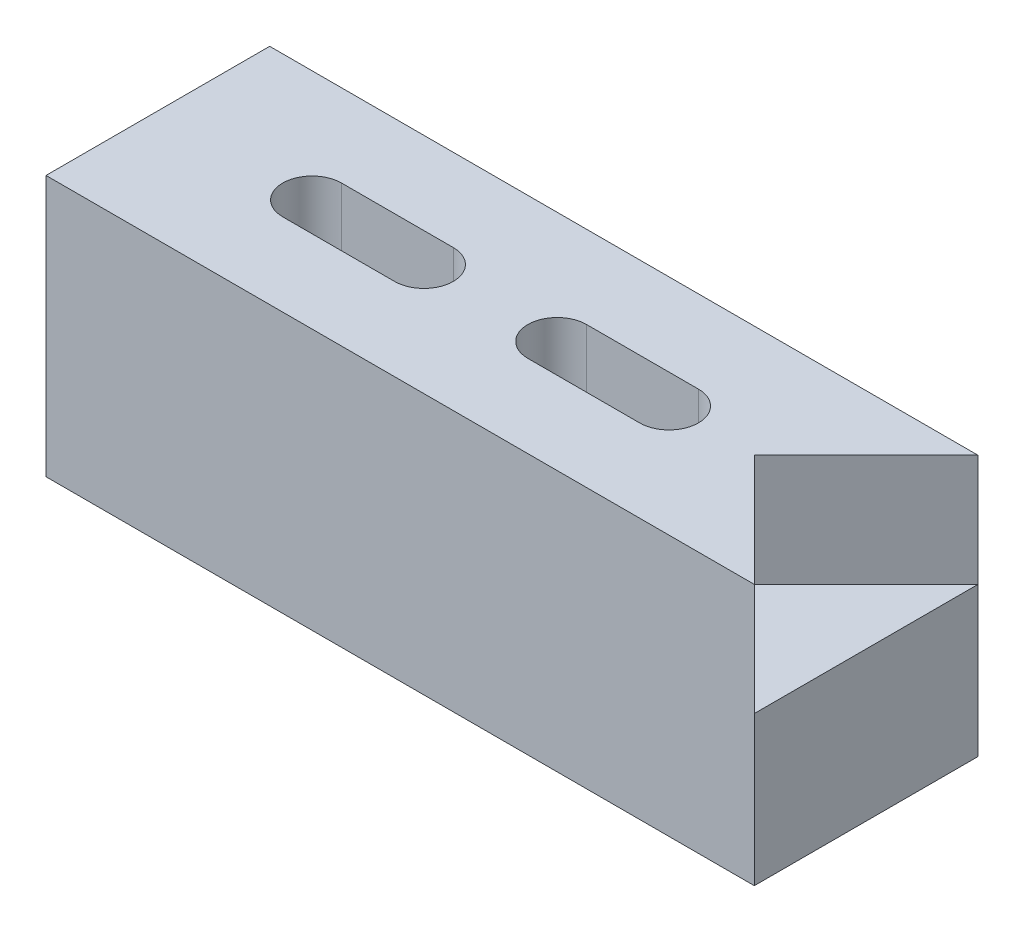
from build123d import *

# Parameters (mm, degrees)
SKETCH1_W           = 48.26
SKETCH1_H           = 17.78
BOSS_EXTRUDE1_DEPTH = 15.24
CUT_EXTRUDE1_DEPTH  = 7.62
CUT_EXTRUDE2_DEPTH  = 18.78


with BuildPart() as part:
    # Sketch1 → Boss-Extrude1 (new body)
    with BuildSketch(Plane.XY):
        with Locations((24.13, 8.89)):
            Rectangle(SKETCH1_W, SKETCH1_H)
    extrude(amount=-BOSS_EXTRUDE1_DEPTH)

    # Sketch3 → Cut-Extrude1 (cut)
    with BuildSketch(Plane(origin=(0, 17.78, 0), x_dir=(1, 0, 0), z_dir=(0, 1, 0))):
        Polygon((48.26, 15.24), (40.64, 7.62), (48.26, 0), align=None)
    extrude(amount=-CUT_EXTRUDE1_DEPTH, mode=Mode.SUBTRACT)

    # Sketch4 → Cut-Extrude2 (cut, through all)
    with BuildSketch(Plane(origin=(0, 17.78, 0), x_dir=(1, 0, 0), z_dir=(0, 1, 0))):
        with BuildLine():
            Line((34.83, 5.62), (27.21, 5.62))
            ThreePointArc((27.21, 5.62), (25.21, 7.62), (27.21, 9.62))
            Line((27.21, 9.62), (34.83, 9.62))
            ThreePointArc((34.83, 9.62), (36.83, 7.62), (34.83, 5.62))
        make_face()
        with BuildLine():
            Line((18.13, 5.62), (10.51, 5.62))
            ThreePointArc((10.51, 5.62), (8.51, 7.62), (10.51, 9.62))
            Line((10.51, 9.62), (18.13, 9.62))
            ThreePointArc((18.13, 9.62), (20.13, 7.62), (18.13, 5.62))
        make_face()
    extrude(amount=-CUT_EXTRUDE2_DEPTH, mode=Mode.SUBTRACT)


solid = part.part
